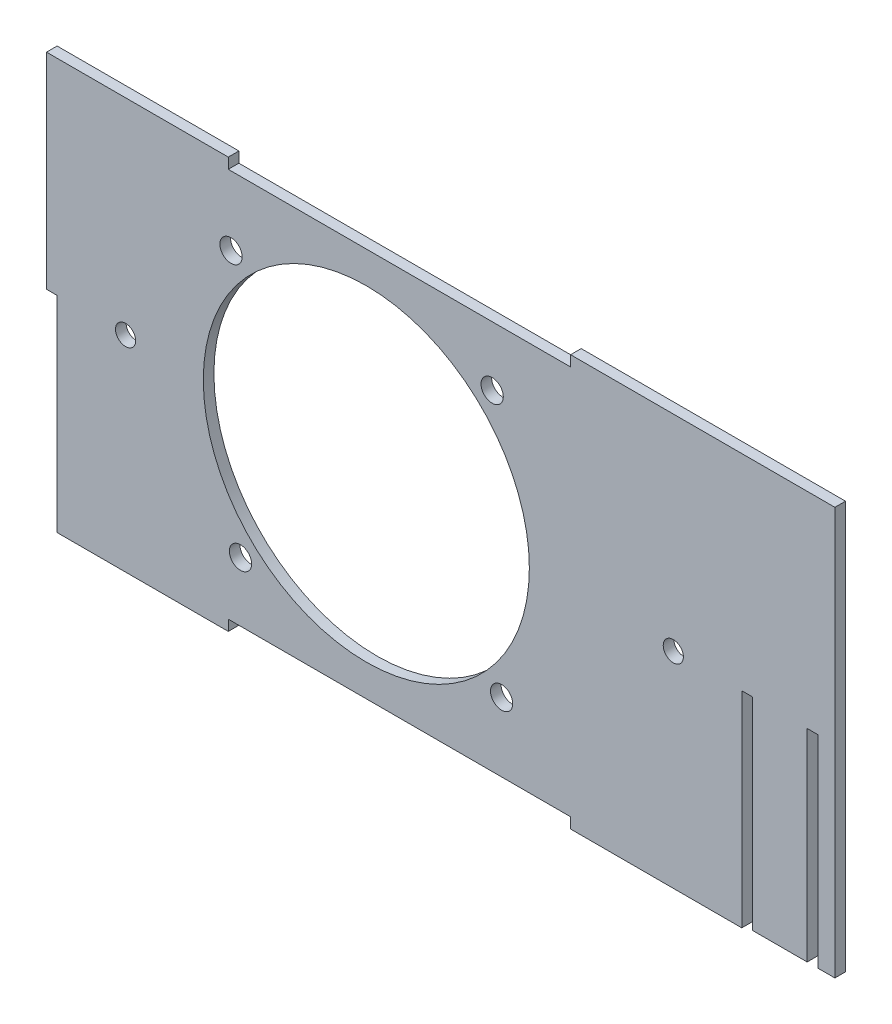
from build123d import *

# Parameters (mm, degrees)
SKETCH1_W           = 200
SKETCH1_H           = 120
SKETCH1_R           = 3.25
SKETCH1_R_2         = 47.625
SKETCH1_R_3         = 2.945643703
BOSS_EXTRUDE1_DEPTH = 3.1
SKETCH2_W           = 3.1
SKETCH2_H           = 60
BOSS_EXTRUDE2_DEPTH = 3.1
SKETCH3_W           = 100
SKETCH3_H           = 3.1
CUT_EXTRUDE1_DEPTH  = 4.1
BOSS_EXTRUDE3_DEPTH = 3.1


with BuildPart() as part:
    # Sketch1 → Boss-Extrude1 (new body)
    with BuildSketch(Plane.XY):
        with Locations((9.675, 0)):
            Rectangle(SKETCH1_W, SKETCH1_H)
        with Locations((-39.522196789, 36.759986207)):
            Circle(SKETCH1_R, mode=Mode.SUBTRACT)
        with Locations((36.759986207, 39.522196789)):
            Circle(SKETCH1_R, mode=Mode.SUBTRACT)
        with Locations((39.522196789, -36.759986207)):
            Circle(SKETCH1_R, mode=Mode.SUBTRACT)
        with Locations((-36.759986207, -39.522196789)):
            Circle(SKETCH1_R, mode=Mode.SUBTRACT)
        Circle(SKETCH1_R_2, mode=Mode.SUBTRACT)
        with Locations((-70.325, 0)):
            Circle(SKETCH1_R_3, mode=Mode.SUBTRACT)
        with Locations((89.675, 0)):
            Circle(SKETCH1_R_3, mode=Mode.SUBTRACT)
    extrude(amount=BOSS_EXTRUDE1_DEPTH)

    # Sketch2 → Boss-Extrude2 (add, through all)
    with BuildSketch(Plane.XY.offset(3.1)):
        with Locations((-91.875, 30)):
            Rectangle(SKETCH2_W, SKETCH2_H)
        with Locations((111.225, 30)):
            Rectangle(SKETCH2_W, SKETCH2_H)
    extrude(amount=-BOSS_EXTRUDE2_DEPTH)

    # Sketch3 → Cut-Extrude1 (cut, through all)
    with BuildSketch(Plane.XY.offset(3.1)):
        with Locations((9.675, -58.45)):
            Rectangle(SKETCH3_W, SKETCH3_H)
        with Locations((9.675, 58.45)):
            Rectangle(SKETCH3_W, SKETCH3_H)
    extrude(amount=-CUT_EXTRUDE1_DEPTH, mode=Mode.SUBTRACT)

    # Sketch4 → Boss-Extrude3 (add, through all)
    with BuildSketch(Plane.XY.offset(3.1)):
        Polygon((112.775, 0), (112.775, -59.080724095), (128.775, -59.080724095), (128.775, 0), (131.875, 0), (131.875, -59.080724095), (136.875, -59.080724095), (136.875, 60), (112.775, 60), align=None)
    extrude(amount=-BOSS_EXTRUDE3_DEPTH)


solid = part.part
